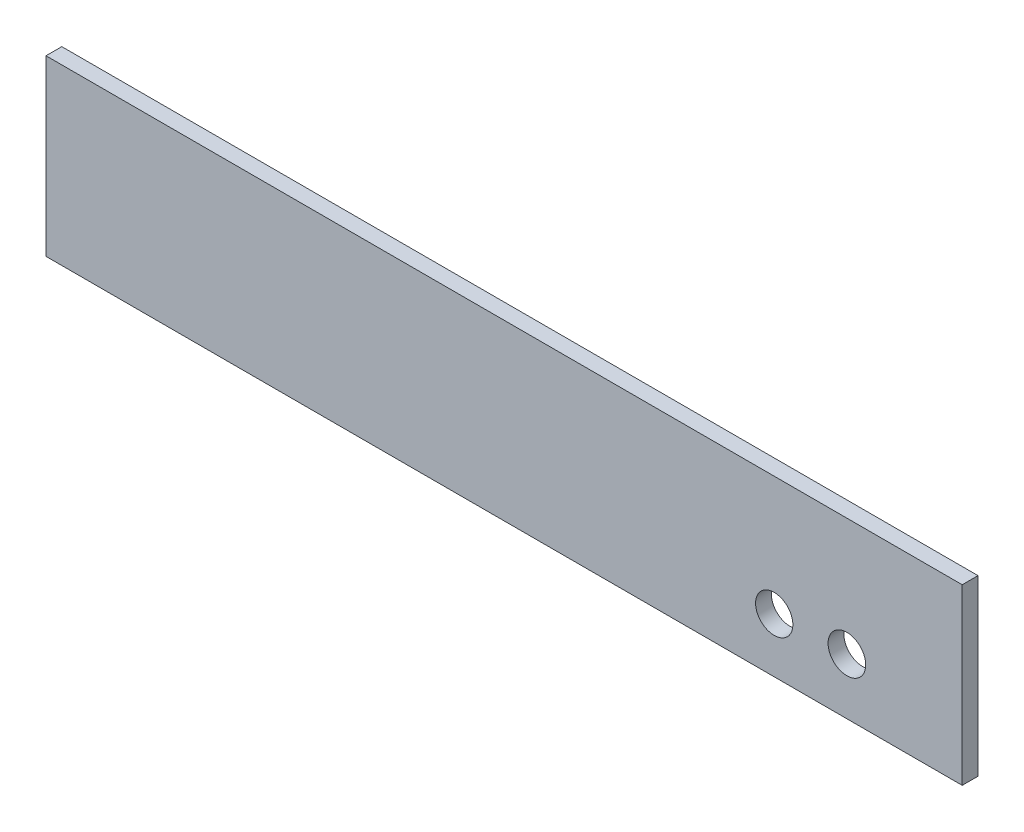
from build123d import *

# Parameters (mm, degrees)
ESQUISSE1_W             = 580
ESQUISSE1_H             = 110
BOSS_EXTRU_1_DEPTH      = 10
ESQUISSE2_R             = 11.8
ESQUISSE2_R_2           = 11.9
ENL_V_MAT_EXTRU_1_DEPTH = 10


with BuildPart() as part:
    # Esquisse1 → Boss.-Extru.1 (new body)
    with BuildSketch(Plane.XY):
        with Locations((290, 55)):
            Rectangle(ESQUISSE1_W, ESQUISSE1_H)
    extrude(amount=BOSS_EXTRU_1_DEPTH)

    # Esquisse2 → Enlèv. mat.-Extru.1 (cut)
    with BuildSketch(Plane(origin=(0, 0, 0), x_dir=(-1, 0, 0), z_dir=(0, 0, -1))):
        with Locations((-461, 34.5)):
            Circle(ESQUISSE2_R)
        with Locations((-507, 35.5)):
            Circle(ESQUISSE2_R_2)
    extrude(amount=-ENL_V_MAT_EXTRU_1_DEPTH, mode=Mode.SUBTRACT)


solid = part.part
